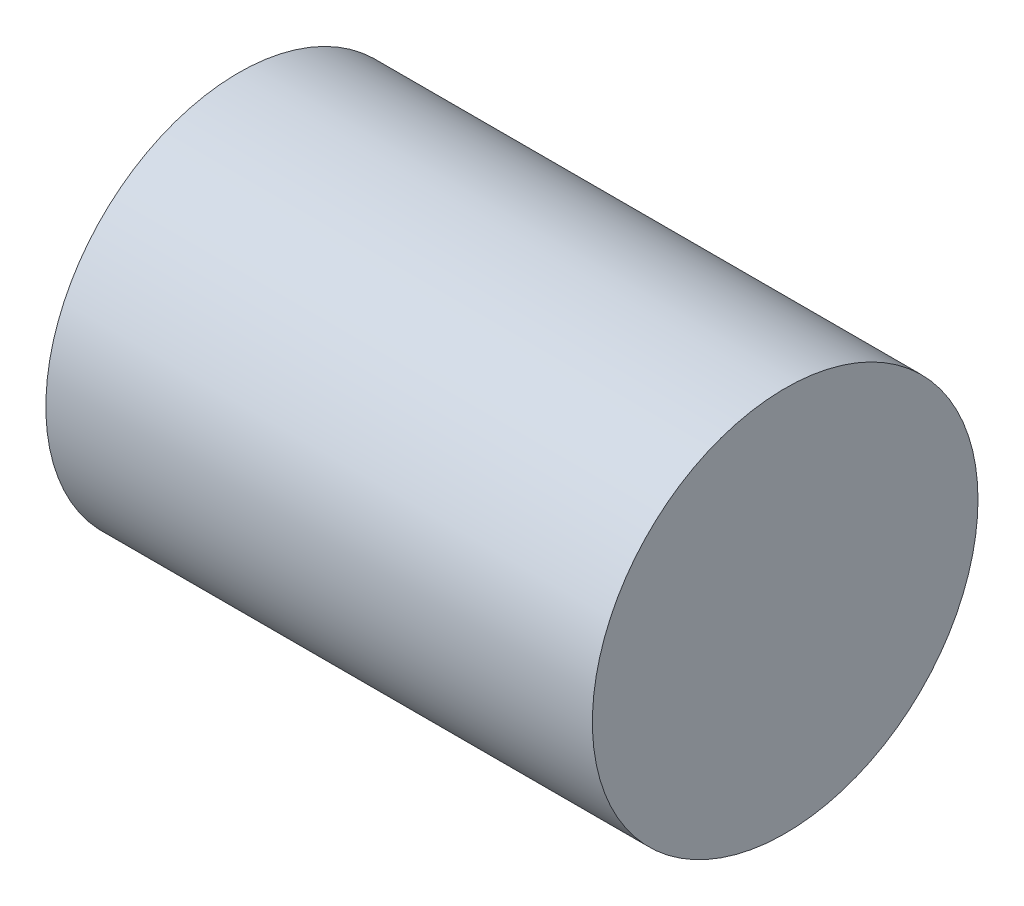
from build123d import *

# Parameters (mm, degrees)
SKETCH2_R           = 1.5875
BOSS_EXTRUDE1_DEPTH = 2.25


with BuildPart() as part:
    # Sketch2 → Boss-Extrude1 (new body, symmetric)
    with BuildSketch(Plane(origin=(0, 0, 0), x_dir=(0, 0, -1), z_dir=(1, 0, 0))):
        Circle(SKETCH2_R)
    extrude(amount=BOSS_EXTRUDE1_DEPTH, both=True)


solid = part.part
